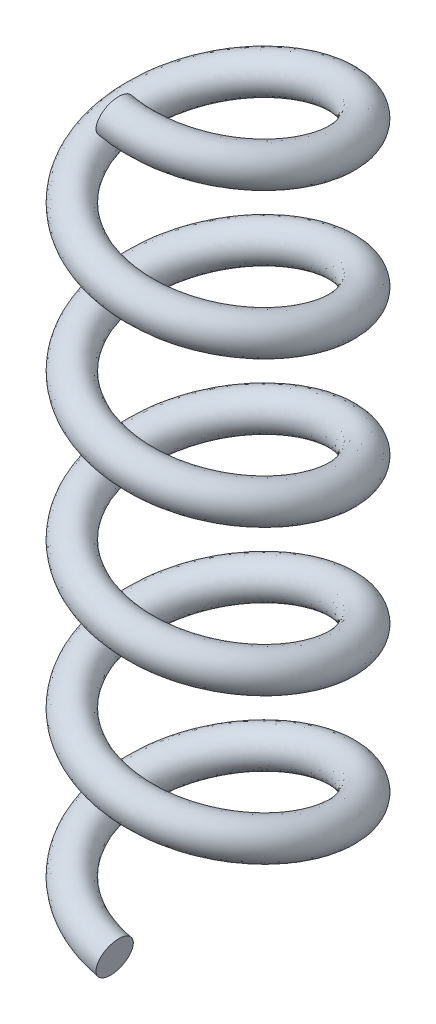
from build123d import *

# Parameters (mm, degrees)
T_HNOUT_PO_K_IVCE1_PITCH  = 60
T_HNOUT_PO_K_IVCE1_HEIGHT = 300
T_HNOUT_PO_K_IVCE1_RADIUS = 42.5
SKICA3_R                  = 7.5


with BuildPart() as part:
    # Táhnout po křivce1: sweep along a helix
    with BuildLine() as t_hnout_po_k_ivce1_path:
        Helix(T_HNOUT_PO_K_IVCE1_PITCH, T_HNOUT_PO_K_IVCE1_HEIGHT, T_HNOUT_PO_K_IVCE1_RADIUS, center=(0, 0, 0), direction=(0, 1, 0), lefthand=True)
    # Skica3 → Táhnout po křivce1 (sweep)
    with BuildSketch(Plane(origin=(0, 0, 42.5), x_dir=(0, 0, 1), z_dir=(-0.975674627, 0.21922368, 0))):
        Circle(SKICA3_R)
    sweep(path=t_hnout_po_k_ivce1_path.line, is_frenet=True)


solid = part.part
